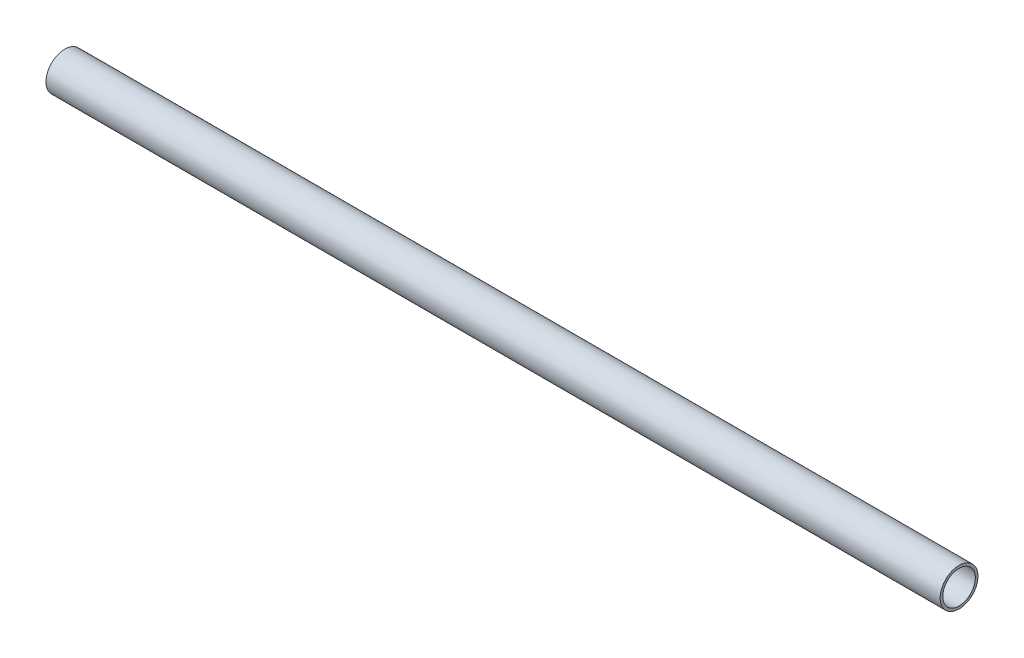
from build123d import *

# Parameters (mm, degrees)
SKETCH_1_W = 300
SKETCH_1_H = 0.889


with BuildPart() as part:
    # 草图1 → 旋转1 (revolve)
    with BuildSketch(Plane.XY):
        with Locations((-300, 5.9055)):
            Rectangle(SKETCH_1_W, SKETCH_1_H)
    revolve(axis=Axis((-450, 0, 0), (1, 0, 0)))


solid = part.part
